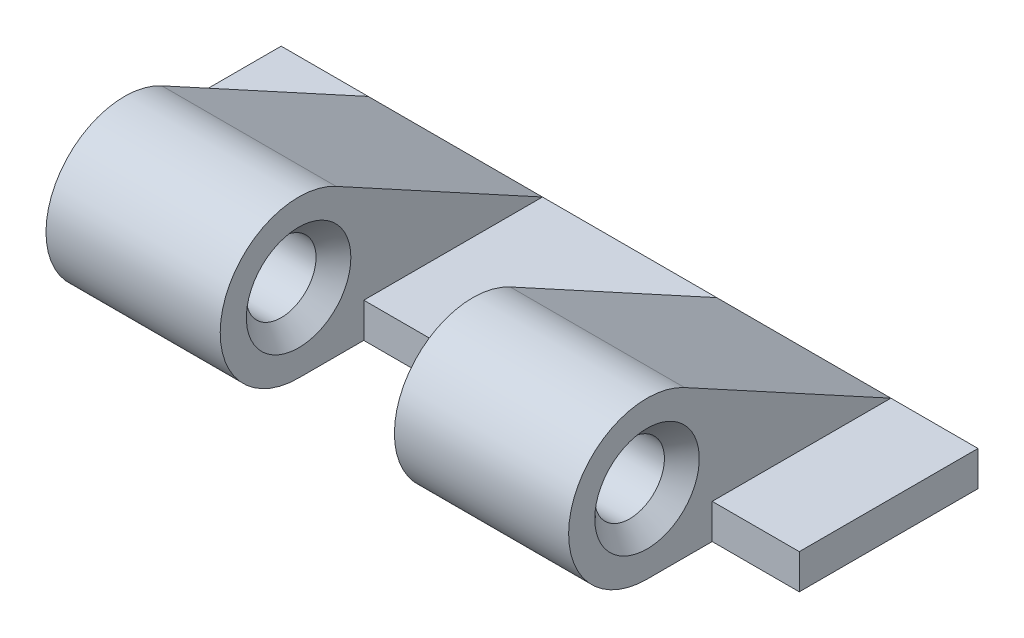
from build123d import *

# Parameters (mm, degrees)
SKIZZE2_W                       = 15
SKIZZE2_H                       = 7
AUFSATZ_LINEAR_AUSTRAGEN1_DEPTH = 1
SKIZZE3_R                       = 2.25
SKIZZE3_R_2                     = 1
AUFSATZ_LINEAR_AUSTRAGEN2_DEPTH = 15
SCHNITT_LINEAR_START            = -5
SCHNITT_LINEAR_AUSTRAGEN1_DEPTH = 5
SKIZZE7_W                       = 5.129171307
SKIZZE7_H                       = 1
AUFSATZ_LINEAR_AUSTRAGEN3_DEPTH = 2.5
FASE1_SIZE                      = 0.5
VERST_RKUNGSFASE_DEPTH          = 5
AUFSATZ_LINEAR_AUSTRAGEN5_DEPTH = 5


with BuildPart() as part:
    # Skizze2 → Aufsatz-Linear austragen1 (new body)
    with BuildSketch(Plane(origin=(0, 0, 0), x_dir=(1, 0, 0), z_dir=(0, 1, 0))):
        Rectangle(SKIZZE2_W, SKIZZE2_H)
    extrude(amount=AUFSATZ_LINEAR_AUSTRAGEN1_DEPTH)

    # Skizze3 → Aufsatz-Linear austragen2 (add)
    with BuildSketch(Plane(origin=(7.5, 0, 0), x_dir=(0, 0, -1), z_dir=(1, 0, 0))):
        with Locations((-3.5, 2.25)):
            Circle(SKIZZE3_R)
        with Locations((-3.5, 2.25)):
            Circle(SKIZZE3_R_2, mode=Mode.SUBTRACT)
    extrude(amount=-AUFSATZ_LINEAR_AUSTRAGEN2_DEPTH)

    # Skizze5 → Schnitt-Linear austragen1 (cut)
    with BuildSketch(Plane(origin=(7.5, 0, 0), x_dir=(0, 0, -1), z_dir=(1, 0, 0)).offset(SCHNITT_LINEAR_START)):
        with BuildLine():
            Line((-1.629171307, 1), (-1.629171307, 0))
            Line((-1.629171307, 0), (-3.5, 0))
            ThreePointArc((-3.5, 0), (-4.560660172, 4.234313483), (-1.629171307, 1))
        make_face()
    extrude(amount=-SCHNITT_LINEAR_AUSTRAGEN1_DEPTH, mode=Mode.SUBTRACT)

    # Skizze7 → Aufsatz-Linear austragen3 (add)
    with BuildSketch(Plane(origin=(7.5, 0, 0), x_dir=(0, 0, -1), z_dir=(1, 0, 0))):
        with Locations((0.935414346, 0.5)):
            Rectangle(SKIZZE7_W, SKIZZE7_H)
    aufsatz_linear_austragen3 = extrude(amount=AUFSATZ_LINEAR_AUSTRAGEN3_DEPTH)

    # Spiegeln1: Aufsatz-Linear austragen3 across plane
    add(aufsatz_linear_austragen3.mirror(Plane(origin=(0, 0, 0), x_dir=(0, 0, 1), z_dir=(1, 0, 0))))

    # Fase1
    fase1_edges = [part.edges().sort_by_distance(p)[0] for p in [
        (-7.5, 2.25, 4.5),
        (7.5, 2.25, 4.5),
        (2.5, 2.25, 4.5),
        (-2.5, 2.25, 4.5),
    ]]
    chamfer(fase1_edges, length=FASE1_SIZE)

    # Skizze8 → Verstärkungsfase (add)
    with BuildSketch(Plane(origin=(7.5, 0, 0), x_dir=(0, 0, -1), z_dir=(1, 0, 0))):
        Polygon((-1.629171307, 1), (3.5, 1), (-2.423928807, 4.225998681), align=None)
    extrude(amount=-VERST_RKUNGSFASE_DEPTH)

    # Skizze9 → Aufsatz-Linear austragen5 (add)
    with BuildSketch(Plane.ZY.offset(7.5)):
        Polygon((1.629171307, 1), (-3.5, 1), (2.423928807, 4.225998681), align=None)
    extrude(amount=-AUFSATZ_LINEAR_AUSTRAGEN5_DEPTH)


solid = part.part
